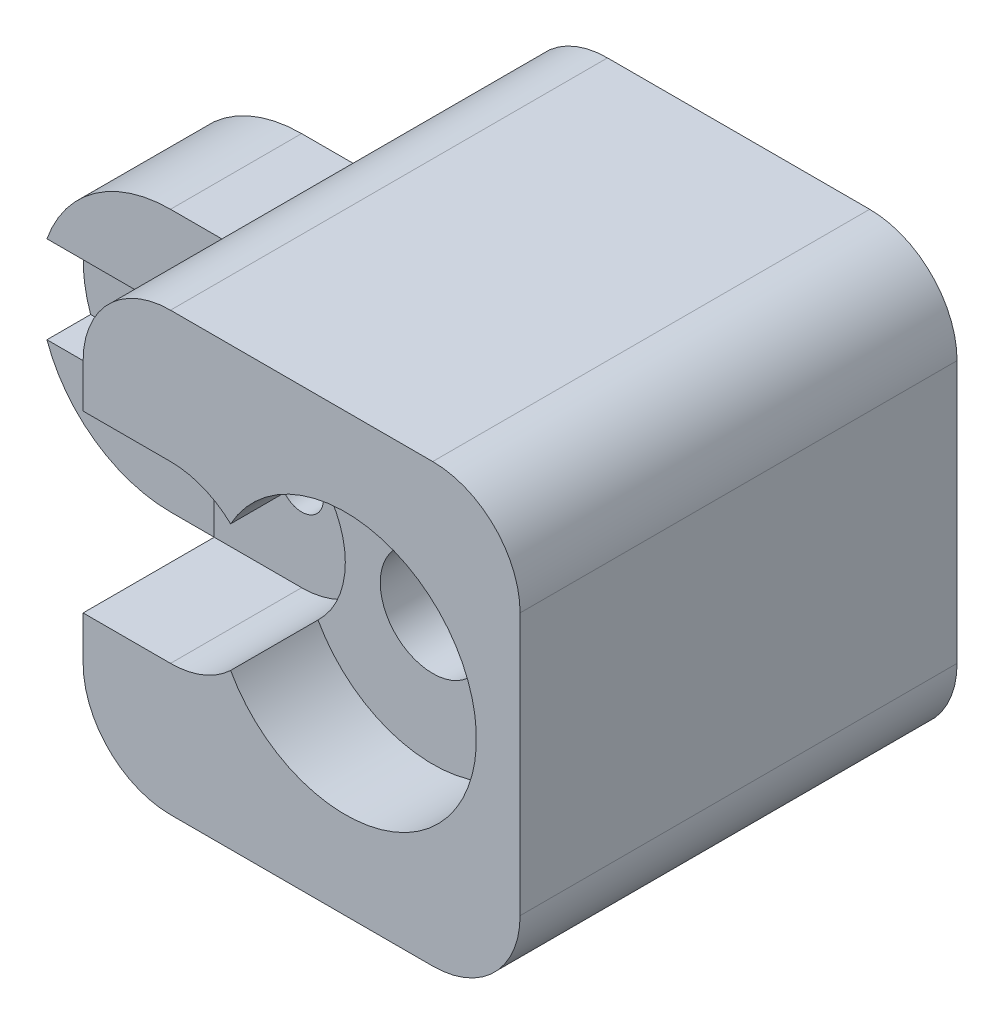
from build123d import *

# Parameters (mm, degrees)
SKETCH1_W           = 100
SKETCH1_H           = 100
BOSS_EXTRUDE1_DEPTH = 100
CUT_EXTRUDE1_DEPTH  = 100
SKETCH3_R           = 12
CUT_EXTRUDE2_DEPTH  = 80
SKETCH5_R           = 5
CUT_EXTRUDE3_DEPTH  = 50
BOSS_EXTRUDE2_DEPTH = 30
SKETCH8_R           = 10
CUT_EXTRUDE4_DEPTH  = 30
CUT_EXTRUDE5_DEPTH  = 10
SKETCH10_R          = 30
CUT_EXTRUDE6_DEPTH  = 96
CUT_EXTRUDE7_DEPTH  = 30
BOSS_EXTRUDE5_DEPTH = 10
SKETCH15_R          = 30
SKETCH15_R_2        = 12
BOSS_EXTRUDE6_DEPTH = 40
SKETCH16_R          = 12
BOSS_EXTRUDE7_DEPTH = 10
CUT_EXTRUDE8_DEPTH  = 10
CUT_EXTRUDE9_DEPTH  = 20


with BuildPart() as part:
    # Sketch1 → Boss-Extrude1 (new body)
    with BuildSketch(Plane.XY):
        with Locations((50, 50)):
            Rectangle(SKETCH1_W, SKETCH1_H)
    extrude(amount=BOSS_EXTRUDE1_DEPTH)

    # Sketch2 → Cut-Extrude1 (cut)
    with BuildSketch(Plane.XY.offset(100)):
        with BuildLine():
            Line((0, 80), (0, 100))
            Line((0, 100), (20, 100))
            ThreePointArc((20, 100), (5.857864376, 94.142135624), (0, 80))
        make_face()
        with BuildLine():
            Line((80, 100), (100, 100))
            Line((100, 100), (100, 80))
            ThreePointArc((100, 80), (94.142135624, 94.142135624), (80, 100))
        make_face()
        with BuildLine():
            Line((80, 0), (100, 0))
            Line((100, 0), (100, 20))
            ThreePointArc((100, 20), (94.142135624, 5.857864376), (80, 0))
        make_face()
        with BuildLine():
            Line((0, 20), (0, 0))
            Line((0, 0), (20, 0))
            ThreePointArc((20, 0), (5.857864376, 5.857864376), (0, 20))
        make_face()
    extrude(amount=-CUT_EXTRUDE1_DEPTH, mode=Mode.SUBTRACT)

    # Sketch3 → Cut-Extrude2 (cut)
    with BuildSketch(Plane(origin=(0, 0, 0), x_dir=(-1, 0, 0), z_dir=(0, 0, -1))):
        with Locations((-60, 50)):
            Circle(SKETCH3_R)
    extrude(amount=-CUT_EXTRUDE2_DEPTH, mode=Mode.SUBTRACT)

    # Sketch5 → Cut-Extrude3 (cut)
    with BuildSketch(Plane.XY.offset(20)):
        with Locations((20, 50)):
            Circle(SKETCH5_R)
    extrude(amount=CUT_EXTRUDE3_DEPTH, mode=Mode.SUBTRACT)

    # Sketch7 → Boss-Extrude2 (add)
    with BuildSketch(Plane.XY.offset(30)):
        with BuildLine():
            Line((0, 80), (-20, 80))
            ThreePointArc((-20, 80), (-50, 50), (-20, 20))
            Line((-20, 20), (0, 20))
            Line((0, 20), (0, 80))
        make_face()
    extrude(amount=BOSS_EXTRUDE2_DEPTH)

    # Sketch8 → Cut-Extrude4 (cut)
    with BuildSketch(Plane.XY.offset(60)):
        with Locations((-20, 50)):
            Circle(SKETCH8_R)
    extrude(amount=-CUT_EXTRUDE4_DEPTH, mode=Mode.SUBTRACT)

    # Sketch9 → Cut-Extrude5 (cut)
    with BuildSketch(Plane.XY.offset(60)):
        with BuildLine():
            Line((-20, 60), (-48.284271247, 60))
            ThreePointArc((-48.284271247, 60), (-50, 50), (-48.284271247, 40))
            Line((-48.284271247, 40), (-20, 40))
            ThreePointArc((-20, 40), (-30, 50), (-20, 60))
        make_face()
    extrude(amount=-CUT_EXTRUDE5_DEPTH, mode=Mode.SUBTRACT)

    # Sketch10 → Cut-Extrude6 (cut)
    with BuildSketch(Plane.XY.offset(30)):
        with Locations(Location((60, 50, 0), (0, 0, 180))):
            Circle(SKETCH10_R)
    extrude(amount=CUT_EXTRUDE6_DEPTH, mode=Mode.SUBTRACT)

    # Sketch11 → Cut-Extrude7 (cut)
    with BuildSketch(Plane.XY.offset(100)):
        with BuildLine():
            Line((20, 70), (0, 70))
            Line((0, 70), (0, 30))
            Line((0, 30), (20, 30))
            ThreePointArc((20, 30), (40, 50), (20, 70))
        make_face()
    extrude(amount=-CUT_EXTRUDE7_DEPTH, mode=Mode.SUBTRACT)

    # Sketch14 → Boss-Extrude5 (add)
    with BuildSketch(Plane.XY.offset(70)):
        with BuildLine():
            Line((20, 55), (20, 70))
            ThreePointArc((20, 70), (40, 50), (20, 30))
            Line((20, 30), (20, 45))
            ThreePointArc((20, 45), (25, 50), (20, 55))
        make_face()
    extrude(amount=BOSS_EXTRUDE5_DEPTH)

    # Sketch15 → Boss-Extrude6 (add)
    with BuildSketch(Plane.XY.offset(30)):
        with Locations((60, 50)):
            Circle(SKETCH15_R)
        with Locations(Location((60, 50, 0), (0, 0, 180))):
            Circle(SKETCH15_R_2, mode=Mode.SUBTRACT)
    extrude(amount=BOSS_EXTRUDE6_DEPTH)

    # Sketch16 → Boss-Extrude7 (add)
    with BuildSketch(Plane.XY.offset(70)):
        with BuildLine():
            ThreePointArc((33.75, 35.476312452), (90, 50), (33.75, 64.523687548))
            ThreePointArc((33.75, 64.523687548), (40, 50), (33.75, 35.476312452))
        make_face()
        with Locations(Location((60, 50, 0), (0, 0, 180))):
            Circle(SKETCH16_R, mode=Mode.SUBTRACT)
    extrude(amount=BOSS_EXTRUDE7_DEPTH)

    # Sketch17 → Cut-Extrude8 (cut)
    with BuildSketch(Plane.XY.offset(80)):
        with BuildLine():
            Line((20, 70), (20, 55))
            ThreePointArc((20, 55), (25, 50), (20, 45))
            Line((20, 45), (20, 30))
            ThreePointArc((20, 30), (27.400211113, 31.419448999), (33.75, 35.476312452))
            ThreePointArc((33.75, 35.476312452), (40, 50), (33.75, 64.523687548))
            ThreePointArc((33.75, 64.523687548), (27.400211113, 68.580551001), (20, 70))
        make_face()
    extrude(amount=-CUT_EXTRUDE8_DEPTH, mode=Mode.SUBTRACT)

    # Sketch18 → Cut-Extrude9 (cut)
    with BuildSketch(Plane(origin=(0, 0, 0), x_dir=(-1, 0, 0), z_dir=(0, 0, -1))):
        with BuildLine():
            Line((0, 70), (-20, 70))
            ThreePointArc((-20, 70), (-40, 50), (-20, 30))
            Line((-20, 30), (0, 30))
            Line((0, 30), (0, 70))
        make_face()
    extrude(amount=-CUT_EXTRUDE9_DEPTH, mode=Mode.SUBTRACT)


solid = part.part
